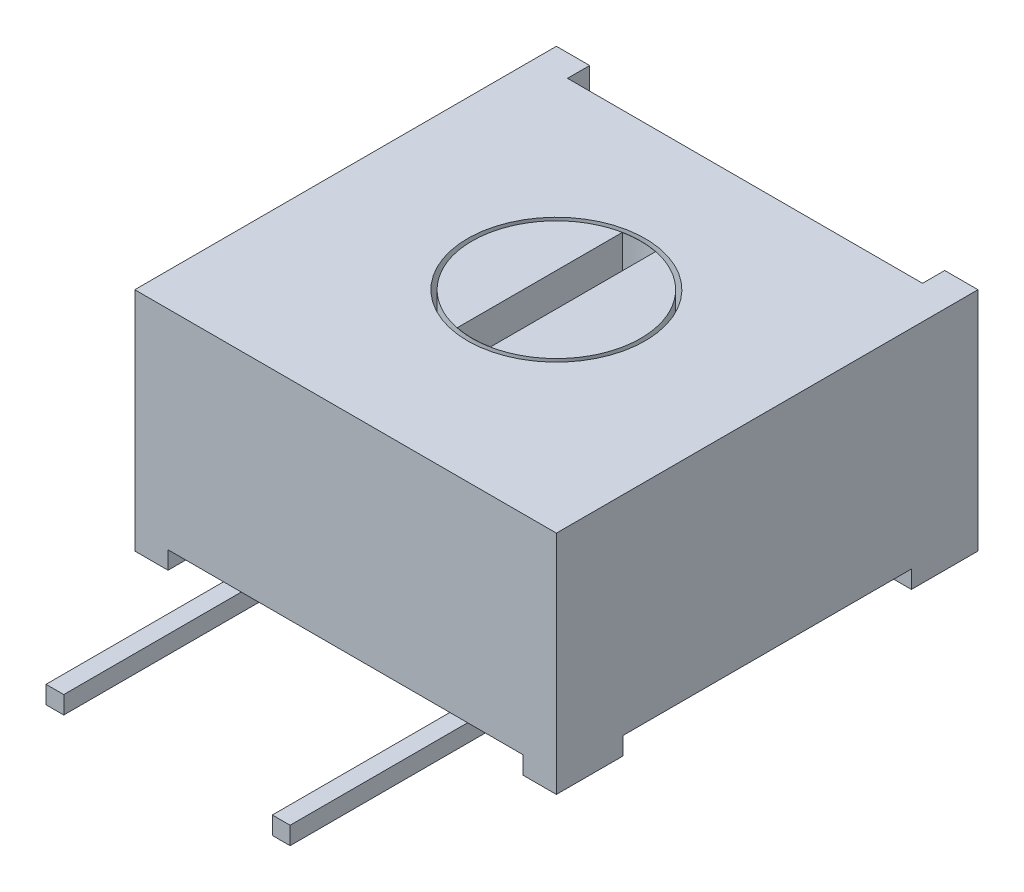
from build123d import *

# Parameters (mm, degrees)
SKETCH1_W               = 9.5
SKETCH1_H               = 9.5
BOSS_EXTRUDE1_DEPTH     = 4.7
SKETCH2_W               = 0.75
SKETCH2_H               = 1.5
BOSS_EXTRUDE2_DEPTH     = 0.4
SKETCH3_W               = 0.4
SKETCH3_H               = 6
BOSS_EXTRUDE3_DEPTH     = 0.4
BOSS_EXTRUDE3_2_DEPTH   = 0.4
BOSS_EXTRUDE3_3_DEPTH   = 0.4
SKETCH4_W               = 8
SKETCH4_H               = 0.5
CUT_EXTRUDE1_DEPTH      = 4.7
SKETCH5_R               = 2
CUT_EXTRUDE2_DEPTH      = 1
CUT_EXTRUDE2_DEPTH_BACK = 2
SKETCH6_R               = 1.9
BOSS_EXTRUDE4_DEPTH     = 2
CUT_EXTRUDE3_DEPTH      = 1


with BuildPart() as part:
    # Sketch1 → Boss-Extrude1 (new body)
    with BuildSketch(Plane(origin=(0, 0, 0), x_dir=(1, 0, 0), z_dir=(0, 1, 0))):
        Rectangle(SKETCH1_W, SKETCH1_H)
    extrude(amount=BOSS_EXTRUDE1_DEPTH)

    # Sketch2 → Boss-Extrude2 (add)
    with BuildSketch(Plane.XZ):
        with Locations((4.375, 4)):
            Rectangle(SKETCH2_W, SKETCH2_H)
        with Locations((-4.375, 4)):
            Rectangle(SKETCH2_W, SKETCH2_H)
        with Locations((4.375, -4)):
            Rectangle(SKETCH2_W, SKETCH2_H)
        with Locations((-4.375, -4)):
            Rectangle(SKETCH2_W, SKETCH2_H)
    extrude(amount=BOSS_EXTRUDE2_DEPTH)

    # Sketch4 → Cut-Extrude1 (cut)
    with BuildSketch(Plane(origin=(0, 4.7, 0), x_dir=(1, 0, 0), z_dir=(0, 1, 0))):
        with Locations((0, 4.5)):
            Rectangle(SKETCH4_W, SKETCH4_H)
    extrude(amount=-CUT_EXTRUDE1_DEPTH, mode=Mode.SUBTRACT)

    # Sketch5 → Cut-Extrude2 (cut, two sides)
    with BuildSketch(Plane(origin=(0, 4.7, 0), x_dir=(1, 0, 0), z_dir=(0, 1, 0))) as cut_extrude2_sk:
        Circle(SKETCH5_R)
    extrude(amount=CUT_EXTRUDE2_DEPTH, mode=Mode.SUBTRACT)
    extrude(cut_extrude2_sk.sketch, amount=-CUT_EXTRUDE2_DEPTH_BACK, mode=Mode.SUBTRACT)


with BuildPart() as body_2:
    # Sketch3 → Boss-Extrude3 (new body)
    with BuildSketch(Plane.XZ):
        with Locations((2.55, 5.75)):
            Rectangle(SKETCH3_W, SKETCH3_H)
    extrude(amount=BOSS_EXTRUDE3_DEPTH)


with BuildPart() as body_3:
    # Sketch3 → Boss-Extrude3 2 (new body)
    with BuildSketch(Plane.XZ):
        with Locations((0, -5.75)):
            Rectangle(SKETCH3_W, SKETCH3_H)
    extrude(amount=BOSS_EXTRUDE3_2_DEPTH)


with BuildPart() as body_4:
    # Sketch3 → Boss-Extrude3 3 (new body)
    with BuildSketch(Plane.XZ):
        with Locations((-2.55, 5.75)):
            Rectangle(SKETCH3_W, SKETCH3_H)
    extrude(amount=BOSS_EXTRUDE3_3_DEPTH)


with BuildPart() as body_5:
    # Sketch6 → Boss-Extrude4 (new body)
    with BuildSketch(Plane(origin=(0, 2.7, 0), x_dir=(1, 0, 0), z_dir=(0, 1, 0))):
        Circle(SKETCH6_R)
    extrude(amount=BOSS_EXTRUDE4_DEPTH)

    # Sketch7 → Cut-Extrude3 (cut)
    with BuildSketch(Plane(origin=(0, 4.7, 0), x_dir=(1, 0, 0), z_dir=(0, 1, 0))):
        with BuildLine():
            Line((0.375, -1.859794894), (0.375, 1.859794894))
            ThreePointArc((0.375, 1.859794894), (0, 1.897224828), (-0.375, 1.859794894))
            Line((-0.375, 1.859794894), (-0.375, -1.859794894))
            ThreePointArc((-0.375, -1.859794894), (0, -1.897224828), (0.375, -1.859794894))
        make_face()
    extrude(amount=-CUT_EXTRUDE3_DEPTH, mode=Mode.SUBTRACT)


solid = Compound([part.part, body_2.part, body_3.part, body_4.part, body_5.part])
